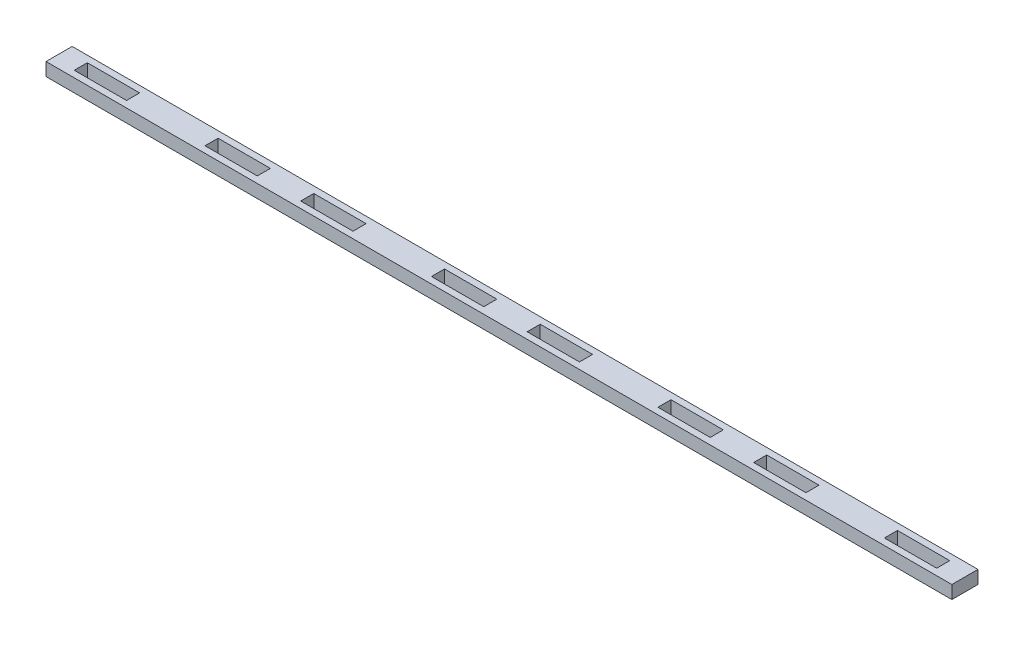
from build123d import *

# Parameters (mm, degrees)
SKETCH1_W           = 439.940905232
SKETCH1_H           = 12.7
BOSS_EXTRUDE1_DEPTH = 6.35
SKETCH2_W           = 25.4
SKETCH2_H           = 6.35
CUT_EXTRUDE1_DEPTH  = 7.35
LPATTERN1_COUNT     = 2
LPATTERN1_PITCH     = 219.970452616
LPATTERN1_COL_COUNT = 2
LPATTERN1_COL_PITCH = 219.970452616


with BuildPart() as part:
    # Sketch1 → Boss-Extrude1 (new body)
    with BuildSketch(Plane(origin=(0, 0, 0), x_dir=(1, 0, 0), z_dir=(0, 1, 0))):
        Rectangle(SKETCH1_W, SKETCH1_H)
    extrude(amount=BOSS_EXTRUDE1_DEPTH)

    # Sketch2 → Cut-Extrude1 (cut, through all)
    with BuildSketch(Plane(origin=(0, 6.35, 0), x_dir=(1, 0, 0), z_dir=(0, 1, 0))):
        with Locations((-23.242613154, 0)):
            Rectangle(SKETCH2_W, SKETCH2_H)
        with Locations((23.242613154, 0)):
            Rectangle(SKETCH2_W, SKETCH2_H)
        with Locations((-86.742613154, 0)):
            Rectangle(SKETCH2_W, SKETCH2_H)
        with Locations((86.742613154, 0)):
            Rectangle(SKETCH2_W, SKETCH2_H)
    cut_extrude1 = extrude(amount=-CUT_EXTRUDE1_DEPTH, mode=Mode.SUBTRACT)

    # LPattern1: Cut-Extrude1 ×2
    with Locations(*[(i * LPATTERN1_PITCH, 0, 0) for i in range(1, LPATTERN1_COUNT)]):
        add(cut_extrude1, mode=Mode.SUBTRACT)

    # LPattern1 col: Cut-Extrude1 ×2
    with Locations(*[(-i * LPATTERN1_COL_PITCH, 0, 0) for i in range(1, LPATTERN1_COL_COUNT)]):
        add(cut_extrude1, mode=Mode.SUBTRACT)


solid = part.part
